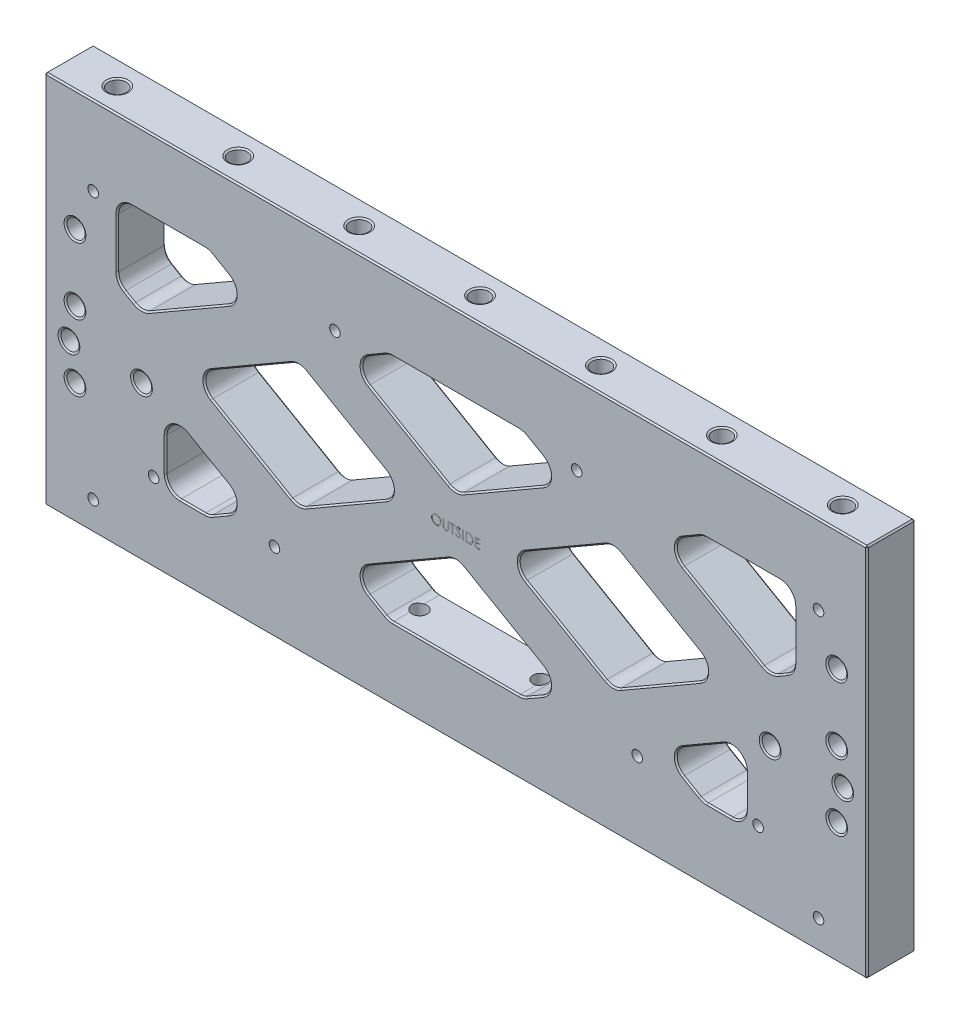
from build123d import *

# Parameters (mm, degrees)
SKETCH1_W                              = 431.8
SKETCH1_H                              = 196.85
EXTRUDE1_DEPTH                         = 25.4
SKETCH8_W                              = 355.6
SKETCH8_H                              = 120.65
EXTRUDE2_DEPTH                         = 26.4
EXTRUDE3_DEPTH                         = 25.4
EXTRUDE16_DEPTH                        = 25.4
FILLET1_R                              = 7.62
CHAMFER2_SIZE                          = 0.762
CHAMFER6_SIZE                          = 0.762
F_3_8_16_TAPPED_HOLE1_AT_2_COUNT       = 2
F_3_8_16_TAPPED_HOLE1_AT_2_PITCH       = 127
F_3_8_16_TAPPED_HOLE1_AT_3_COUNT       = 2
F_3_8_16_TAPPED_HOLE1_AT_3_PITCH       = 254
F_3_8_16_TAPPED_HOLE2_AT_2_COUNT       = 2
F_3_8_16_TAPPED_HOLE2_AT_2_PITCH       = 127
F_3_8_16_TAPPED_HOLE2_AT_3_COUNT       = 2
F_3_8_16_TAPPED_HOLE2_AT_3_PITCH       = 127
F_3_8_16_TAPPED_HOLE2_AT_4_COUNT       = 2
F_3_8_16_TAPPED_HOLE2_AT_4_PITCH       = 254
F_3_8_16_TAPPED_HOLE3_AT_2_COUNT       = 2
F_3_8_16_TAPPED_HOLE3_AT_2_PITCH       = 63.5
F_3_8_16_TAPPED_HOLE4_AT_2_COUNT       = 2
F_3_8_16_TAPPED_HOLE4_AT_2_PITCH       = 63.5
F_3_8_16_TAPPED_HOLE4_AT_3_COUNT       = 2
F_3_8_16_TAPPED_HOLE4_AT_3_PITCH       = 254
F_3_8_16_TAPPED_HOLE4_AT_4_COUNT       = 2
F_3_8_16_TAPPED_HOLE4_AT_4_PITCH       = 317.5
F_7_32_0_21875_DIAMETER_HOLE1_D        = 5.55625
F_3_8_16_TAPPED_HOLE5_AT_2_COUNT       = 2
F_3_8_16_TAPPED_HOLE5_AT_2_PITCH       = 34.925
F_3_8_16_TAPPED_HOLE5_AT_3_COUNT       = 2
F_3_8_16_TAPPED_HOLE5_AT_3_PITCH       = 69.85
F_3_8_16_TAPPED_HOLE5_AT_4_COUNT       = 2
F_3_8_16_TAPPED_HOLE5_AT_4_PITCH       = 400.05
F_3_8_16_TAPPED_HOLE5_AT_5_COUNT       = 2
F_3_8_16_TAPPED_HOLE5_AT_5_PITCH       = 401.571610208
F_3_8_16_TAPPED_HOLE5_AT_6_COUNT       = 2
F_3_8_16_TAPPED_HOLE5_AT_6_PITCH       = 406.102234665
F_3_8_16_TAPPED_HOLE6_AT_2_COUNT       = 2
F_3_8_16_TAPPED_HOLE6_AT_2_PITCH       = 38.1
F_3_8_16_TAPPED_HOLE6_AT_3_COUNT       = 2
F_3_8_16_TAPPED_HOLE6_AT_3_PITCH       = 368.3
F_3_8_16_TAPPED_HOLE6_AT_4_COUNT       = 2
F_3_8_16_TAPPED_HOLE6_AT_4_PITCH       = 406.4
F_3_8_0_375_DIAMETER_HOLE1_D           = 9.54278
F_3_8_0_375_DIAMETER_HOLE1_DEPTH       = 19.05
F_3_8_0_375_DIAMETER_HOLE1_CSINK_D     = 14.224
F_3_8_0_375_DIAMETER_HOLE1_CSINK_ANGLE = 90
F_3_8_0_375_DIAMETER_HOLE1_TIP         = 2.866940349
EXTRUDE15_DEPTH                        = 19.05
CHAMFER5_SIZE                          = 2.286
F_7_32_0_21875_DIAMETER_HOLE2_D        = 5.55625
SKETCH59_W                             = 0.427403846
SKETCH59_H                             = 4.7625
EXTRUDE17_DEPTH                        = 0.0254


with BuildPart() as part:
    # Sketch1 → Extrude1 (new body)
    with BuildSketch(Plane.XY):
        with Locations((0, 98.425)):
            Rectangle(SKETCH1_W, SKETCH1_H)
    extrude(amount=EXTRUDE1_DEPTH)

    # Sketch8 → Extrude2 (cut, through all)
    with BuildSketch(Plane.XY.offset(25.4)):
        with Locations((0, 98.425)):
            Rectangle(SKETCH8_W, SKETCH8_H)
    extrude(amount=-EXTRUDE2_DEPTH, mode=Mode.SUBTRACT)

    # Sketch9 → Extrude3 (add)
    with BuildSketch(Plane.XY.offset(25.4)):
        Polygon((-129.885964967, 158.75), (79.085964967, 38.1), (129.885964967, 38.1), (-79.085964967, 158.75), align=None)
        Polygon((-177.8, 91.092651581), (-86.014035033, 38.1), (-35.214035033, 38.1), (-177.8, 120.422045256), align=None)
        Polygon((35.214035033, 158.75), (177.8, 76.427954744), (177.8, 105.757348419), (86.014035033, 158.75), align=None)
    extrude3 = extrude(amount=-EXTRUDE3_DEPTH)

    # Mirror2: Extrude3 across plane
    add(extrude3.mirror(Plane(origin=(0, 0, 0), x_dir=(0, 0, 1), z_dir=(1, 0, 0))))

    # Sketch56 → Extrude16 (add)
    with BuildSketch(Plane.XY.offset(25.4)):
        Polygon((-177.8, 76.427954744), (-177.8, 38.1), (-152.4, 38.1), (-152.4, 76.427954744), (-165.1, 83.760303163), align=None)
        Polygon((165.1, 83.760303163), (177.8, 76.427954744), (177.8, 38.1), (152.4, 38.1), (152.4, 76.427954744), align=None)
    extrude(amount=-EXTRUDE16_DEPTH)

    # Fillet1
    fillet1_edges = [part.edges().sort_by_distance(p)[0] for p in [
        (82.55, 65.429432116, 12.7),
        (57.15, 50.764735278, 12.7),
        (165.1, 113.089696837, 12.7),
        (139.7, 98.425, 12.7),
        (107.95, 50.764735278, 12.7),
        (35.214035033, 38.1, 12.7),
        (177.8, 120.422045256, 12.7),
        (-107.95, 146.085264722, 12.7),
        (-165.1, 113.089696837, 12.7),
        (-57.15, 146.085264722, 12.7),
        (-82.55, 131.420567884, 12.7),
        (-35.214035033, 158.75, 12.7),
        (-139.7, 98.425, 12.7),
        (-177.8, 158.75, 12.7),
        (177.8, 158.75, 12.7),
        (-152.4, 76.427954744, 12.7),
        (-152.4, 38.1, 12.7),
        (152.4, 76.427954744, 12.7),
        (152.4, 38.1, 12.7),
        (-129.885964967, 158.75, 12.7),
        (129.885964967, 38.1, 12.7),
        (-177.8, 120.422045256, 12.7),
        (-35.214035033, 38.1, 12.7),
        (35.214035033, 158.75, 12.7),
        (82.55, 131.420567884, 12.7),
        (57.15, 146.085264722, 12.7),
        (0, 113.089696837, 12.7),
        (-25.4, 98.425, 12.7),
        (-82.55, 65.429432116, 12.7),
        (-107.95, 50.764735278, 12.7),
        (25.4, 98.425, 12.7),
        (0, 83.760303163, 12.7),
        (-57.15, 50.764735278, 12.7),
        (107.95, 146.085264722, 12.7),
        (129.885964967, 158.75, 12.7),
        (-129.885964967, 38.1, 12.7),
    ]]
    fillet(fillet1_edges, radius=FILLET1_R)

    # Chamfer2
    chamfer2_edges = [part.edges().sort_by_distance(p)[0] for p in [
        (215.9, 98.425, 25.4),
        (0, 196.85, 25.4),
        (-215.9, 98.425, 25.4),
        (0, 196.85, 0),
        (215.9, 98.425, 0),
        (0, 0, 0),
        (-215.9, 98.425, 0),
        (0, 0, 25.4),
        (-215.9, 196.85, 12.7),
        (215.9, 196.85, 12.7),
        (215.9, 0, 12.7),
        (-215.9, 0, 12.7),
    ]]
    chamfer(chamfer2_edges, length=CHAMFER2_SIZE)

    # Chamfer6
    chamfer6_edges = [part.edges().sort_by_distance(p)[0] for p in [
        (152.4, 54.474863795, 0),
        (152.4, 54.474863795, 25.4),
        (138.353868906, 38.1, 25.4),
        (138.353868906, 38.1, 0),
        (130.175, 63.596345011, 0),
        (130.175, 63.596345011, 25.4),
        (-138.353868906, 38.1, 0),
        (-138.353868906, 38.1, 25.4),
        (-152.4, 54.474863795, 0),
        (-152.4, 54.474863795, 25.4),
        (-130.175, 63.596345011, 0),
        (-130.175, 63.596345011, 25.4),
        (140.335, 127.387776254, 25.4),
        (140.335, 127.387776254, 0),
        (123.748868906, 155.206745938, 0),
        (123.748868906, 155.206745938, 25.4),
        (151.053868906, 158.75, 0),
        (151.053868906, 158.75, 25.4),
        (177.8, 137.975727154, 25.4),
        (177.8, 137.975727154, 0),
        (171.45, 116.755871047, 25.4),
        (171.45, 116.755871047, 0),
        (57.785, 79.727511532, 25.4),
        (57.785, 79.727511532, 0),
        (57.785, 117.122488468, 0),
        (57.785, 117.122488468, 25.4),
        (107.315, 117.122488468, 0),
        (107.315, 117.122488468, 25.4),
        (107.315, 79.727511532, 25.4),
        (107.315, 79.727511532, 0),
        (41.351131094, 41.643254062, 0),
        (41.351131094, 41.643254062, 25.4),
        (0, 38.1, 0),
        (0, 38.1, 25.4),
        (-41.351131094, 41.643254062, 0),
        (-41.351131094, 41.643254062, 25.4),
        (-24.765, 69.462223746, 25.4),
        (-24.765, 69.462223746, 0),
        (24.765, 69.462223746, 0),
        (24.765, 69.462223746, 25.4),
        (123.748868906, 41.643254062, 0),
        (123.748868906, 41.643254062, 25.4),
        (-123.748868906, 41.643254062, 0),
        (-123.748868906, 41.643254062, 25.4),
        (-57.785, 117.122488468, 25.4),
        (-57.785, 117.122488468, 0),
        (-57.785, 79.727511532, 0),
        (-57.785, 79.727511532, 25.4),
        (-107.315, 79.727511532, 0),
        (-107.315, 79.727511532, 25.4),
        (-107.315, 117.122488468, 25.4),
        (-107.315, 117.122488468, 0),
        (-171.45, 116.755871047, 25.4),
        (-171.45, 116.755871047, 0),
        (-140.335, 127.387776254, 0),
        (-140.335, 127.387776254, 25.4),
        (-177.8, 137.975727154, 25.4),
        (-177.8, 137.975727154, 0),
        (-151.053868906, 158.75, 0),
        (-151.053868906, 158.75, 25.4),
        (-123.748868906, 155.206745938, 0),
        (-123.748868906, 155.206745938, 25.4),
        (-41.351131094, 155.206745938, 0),
        (-41.351131094, 155.206745938, 25.4),
        (0, 158.75, 0),
        (0, 158.75, 25.4),
        (41.351131094, 155.206745938, 0),
        (41.351131094, 155.206745938, 25.4),
        (24.765, 127.387776254, 25.4),
        (24.765, 127.387776254, 0),
        (-24.765, 127.387776254, 0),
        (-24.765, 127.387776254, 25.4),
        (150.168153673, 40.331846327, 25.4),
        (150.168153673, 40.331846327, 0),
        (148.59, 69.828841167, 25.4),
        (148.59, 69.828841167, 0),
        (-150.168153673, 40.331846327, 25.4),
        (-150.168153673, 40.331846327, 0),
        (-148.59, 69.828841167, 25.4),
        (-148.59, 69.828841167, 0),
        (115.57, 146.085264722, 25.4),
        (115.57, 146.085264722, 0),
        (129.955536689, 158.490354796, 25.4),
        (129.955536689, 158.490354796, 0),
        (175.568153673, 156.518153673, 25.4),
        (175.568153673, 156.518153673, 0),
        (176.779113577, 121.011454307, 25.4),
        (176.779113577, 121.011454307, 0),
        (165.1, 114.26851494, 0),
        (165.1, 114.26851494, 25.4),
        (33.02, 98.425, 25.4),
        (33.02, 98.425, 0),
        (82.55, 130.241749782, 0),
        (82.55, 130.241749782, 25.4),
        (132.08, 98.425, 25.4),
        (132.08, 98.425, 0),
        (82.55, 66.608250218, 0),
        (82.55, 66.608250218, 25.4),
        (35.144463311, 38.359645204, 25.4),
        (35.144463311, 38.359645204, 0),
        (-35.144463311, 38.359645204, 25.4),
        (-35.144463311, 38.359645204, 0),
        (-49.53, 50.764735278, 25.4),
        (-49.53, 50.764735278, 0),
        (0, 82.58148506, 0),
        (0, 82.58148506, 25.4),
        (49.53, 50.764735278, 25.4),
        (49.53, 50.764735278, 0),
        (129.955536689, 38.359645204, 25.4),
        (129.955536689, 38.359645204, 0),
        (115.57, 50.764735278, 25.4),
        (115.57, 50.764735278, 0),
        (-115.57, 50.764735278, 25.4),
        (-115.57, 50.764735278, 0),
        (-129.955536689, 38.359645204, 25.4),
        (-129.955536689, 38.359645204, 0),
        (-33.02, 98.425, 25.4),
        (-33.02, 98.425, 0),
        (-82.55, 66.608250218, 0),
        (-82.55, 66.608250218, 25.4),
        (-82.55, 130.241749782, 0),
        (-82.55, 130.241749782, 25.4),
        (-165.1, 114.26851494, 0),
        (-165.1, 114.26851494, 25.4),
        (-176.779113577, 121.011454307, 25.4),
        (-176.779113577, 121.011454307, 0),
        (-175.568153673, 156.518153673, 25.4),
        (-175.568153673, 156.518153673, 0),
        (-129.955536689, 158.490354796, 25.4),
        (-129.955536689, 158.490354796, 0),
        (-115.57, 146.085264722, 25.4),
        (-115.57, 146.085264722, 0),
        (-35.144463311, 158.490354796, 25.4),
        (-35.144463311, 158.490354796, 0),
        (35.144463311, 158.490354796, 25.4),
        (35.144463311, 158.490354796, 0),
        (49.53, 146.085264722, 25.4),
        (49.53, 146.085264722, 0),
        (0, 114.26851494, 0),
        (0, 114.26851494, 25.4),
        (-49.53, 146.085264722, 25.4),
        (-49.53, 146.085264722, 0),
        (-132.08, 98.425, 25.4),
        (-132.08, 98.425, 0),
    ]]
    chamfer(chamfer6_edges, length=CHAMFER6_SIZE)

    # Sketch6 → 3/8-16 Tapped Hole1 (revolve, cut)
    with BuildSketch(Plane(origin=(-127, 196.85, 12.7), x_dir=(0, 0, 1), z_dir=(1, 0, 0))):
        Polygon((0, 0), (0, 45.564665582), (3.96875, 43.18), (3.96875, 25.4), (4.7625, 25.4), (4.7625, 0.549926131), (5.715, 0), align=None)
    f_3_8_16_tapped_hole1 = revolve(axis=Axis((-127, 203.2, 12.7), (0, -1, 0)), mode=Mode.SUBTRACT)

    # 3/8-16 Tapped Hole1 at 2: 3/8-16 Tapped Hole1 ×2
    with Locations(*[(i * F_3_8_16_TAPPED_HOLE1_AT_2_PITCH, 0, 0) for i in range(1, F_3_8_16_TAPPED_HOLE1_AT_2_COUNT)]):
        add(f_3_8_16_tapped_hole1, mode=Mode.SUBTRACT)

    # 3/8-16 Tapped Hole1 at 3: 3/8-16 Tapped Hole1 ×2
    with Locations(*[(i * F_3_8_16_TAPPED_HOLE1_AT_3_PITCH, 0, 0) for i in range(1, F_3_8_16_TAPPED_HOLE1_AT_3_COUNT)]):
        add(f_3_8_16_tapped_hole1, mode=Mode.SUBTRACT)

    # Sketch48 → 3/8-16 Tapped Hole2 (revolve, cut)
    with BuildSketch(Plane(origin=(63.5, 196.85, 12.7), x_dir=(0, 0, 1), z_dir=(1, 0, 0))):
        Polygon((0, 0), (0, 45.564665582), (3.96875, 43.18), (3.96875, 25.4), (4.7625, 25.4), (4.7625, 0.549926131), (5.715, 0), align=None)
    f_3_8_16_tapped_hole2 = revolve(axis=Axis((63.5, 203.2, 12.7), (0, -1, 0)), mode=Mode.SUBTRACT)

    # 3/8-16 Tapped Hole2 at 2: 3/8-16 Tapped Hole2 ×2
    with Locations(*[(-i * F_3_8_16_TAPPED_HOLE2_AT_2_PITCH, 0, 0) for i in range(1, F_3_8_16_TAPPED_HOLE2_AT_2_COUNT)]):
        add(f_3_8_16_tapped_hole2, mode=Mode.SUBTRACT)

    # 3/8-16 Tapped Hole2 at 3: 3/8-16 Tapped Hole2 ×2
    with Locations(*[(i * F_3_8_16_TAPPED_HOLE2_AT_3_PITCH, 0, 0) for i in range(1, F_3_8_16_TAPPED_HOLE2_AT_3_COUNT)]):
        add(f_3_8_16_tapped_hole2, mode=Mode.SUBTRACT)

    # 3/8-16 Tapped Hole2 at 4: 3/8-16 Tapped Hole2 ×2
    with Locations(*[(-i * F_3_8_16_TAPPED_HOLE2_AT_4_PITCH, 0, 0) for i in range(1, F_3_8_16_TAPPED_HOLE2_AT_4_COUNT)]):
        add(f_3_8_16_tapped_hole2, mode=Mode.SUBTRACT)

    # Sketch26 → 3/8-16 Tapped Hole3 (revolve, cut)
    with BuildSketch(Plane(origin=(-31.75, 0, 12.7), x_dir=(0, 0, -1), z_dir=(1, 0, 0))):
        Polygon((0, 0), (0, 45.564665582), (3.96875, 43.18), (3.96875, 25.4), (4.7625, 25.4), (4.7625, 0.549926131), (5.715, 0), align=None)
    f_3_8_16_tapped_hole3 = revolve(axis=Axis((-31.75, -6.35, 12.7), (0, 1, 0)), mode=Mode.SUBTRACT)

    # 3/8-16 Tapped Hole3 at 2: 3/8-16 Tapped Hole3 ×2
    with Locations(*[(i * F_3_8_16_TAPPED_HOLE3_AT_2_PITCH, 0, 0) for i in range(1, F_3_8_16_TAPPED_HOLE3_AT_2_COUNT)]):
        add(f_3_8_16_tapped_hole3, mode=Mode.SUBTRACT)

    # Sketch32 → 3/8-16 Tapped Hole4 (revolve, cut)
    with BuildSketch(Plane(origin=(-158.75, 0, 12.7), x_dir=(0, 0, -1), z_dir=(1, 0, 0))):
        Polygon((0, 0), (0, 45.564665582), (3.96875, 43.18), (3.96875, 25.4), (4.7625, 25.4), (4.7625, 0.549926131), (5.715, 0), align=None)
    f_3_8_16_tapped_hole4 = revolve(axis=Axis((-158.75, -6.35, 12.7), (0, 1, 0)), mode=Mode.SUBTRACT)

    # 3/8-16 Tapped Hole4 at 2: 3/8-16 Tapped Hole4 ×2
    with Locations(*[(i * F_3_8_16_TAPPED_HOLE4_AT_2_PITCH, 0, 0) for i in range(1, F_3_8_16_TAPPED_HOLE4_AT_2_COUNT)]):
        add(f_3_8_16_tapped_hole4, mode=Mode.SUBTRACT)

    # 3/8-16 Tapped Hole4 at 3: 3/8-16 Tapped Hole4 ×2
    with Locations(*[(i * F_3_8_16_TAPPED_HOLE4_AT_3_PITCH, 0, 0) for i in range(1, F_3_8_16_TAPPED_HOLE4_AT_3_COUNT)]):
        add(f_3_8_16_tapped_hole4, mode=Mode.SUBTRACT)

    # 3/8-16 Tapped Hole4 at 4: 3/8-16 Tapped Hole4 ×2
    with Locations(*[(i * F_3_8_16_TAPPED_HOLE4_AT_4_PITCH, 0, 0) for i in range(1, F_3_8_16_TAPPED_HOLE4_AT_4_COUNT)]):
        add(f_3_8_16_tapped_hole4, mode=Mode.SUBTRACT)

    # 7/32 (0.21875) Diameter Hole1 (through all)
    with Locations(Plane.XY.offset(25.4)):
        with Locations((-190.5, 155.448), (-63.5, 155.448), (63.5, 155.448), (190.5, 155.448), (-158.75, 41.402), (-95.25, 41.402), (95.25, 41.402), (158.75, 41.402)):
            Hole(F_7_32_0_21875_DIAMETER_HOLE1_D / 2)

    # Sketch28 → 3/8-16 Tapped Hole5 (revolve, cut)
    with BuildSketch(Plane(origin=(200.025, 133.35, 0), x_dir=(0, 1, 0), z_dir=(1, 0, 0))):
        Polygon((0, 0), (0, 25.4), (5.715, 25.4), (4.7625, 24.850073869), (4.7625, 0.549926131), (5.715, 0), align=None)
    f_3_8_16_tapped_hole5 = revolve(axis=Axis((200.025, 133.35, -6.35), (0, 0, 1)), mode=Mode.SUBTRACT)

    # 3/8-16 Tapped Hole5 at 2: 3/8-16 Tapped Hole5 ×2
    with Locations(*[(0, -i * F_3_8_16_TAPPED_HOLE5_AT_2_PITCH, 0) for i in range(1, F_3_8_16_TAPPED_HOLE5_AT_2_COUNT)]):
        add(f_3_8_16_tapped_hole5, mode=Mode.SUBTRACT)

    # 3/8-16 Tapped Hole5 at 3: 3/8-16 Tapped Hole5 ×2
    with Locations(*[(0, -i * F_3_8_16_TAPPED_HOLE5_AT_3_PITCH, 0) for i in range(1, F_3_8_16_TAPPED_HOLE5_AT_3_COUNT)]):
        add(f_3_8_16_tapped_hole5, mode=Mode.SUBTRACT)

    # 3/8-16 Tapped Hole5 at 4: 3/8-16 Tapped Hole5 ×2
    with Locations(*[(-i * F_3_8_16_TAPPED_HOLE5_AT_4_PITCH, 0, 0) for i in range(1, F_3_8_16_TAPPED_HOLE5_AT_4_COUNT)]):
        add(f_3_8_16_tapped_hole5, mode=Mode.SUBTRACT)

    # 3/8-16 Tapped Hole5 at 5: 3/8-16 Tapped Hole5 ×2
    with Locations(*[Vector(-0.996210862, -0.08697079, 0) * (i * F_3_8_16_TAPPED_HOLE5_AT_5_PITCH) for i in range(1, F_3_8_16_TAPPED_HOLE5_AT_5_COUNT)]):
        add(f_3_8_16_tapped_hole5, mode=Mode.SUBTRACT)

    # 3/8-16 Tapped Hole5 at 6: 3/8-16 Tapped Hole5 ×2
    with Locations(*[Vector(-0.985096771, -0.172001023, 0) * (i * F_3_8_16_TAPPED_HOLE5_AT_6_PITCH) for i in range(1, F_3_8_16_TAPPED_HOLE5_AT_6_COUNT)]):
        add(f_3_8_16_tapped_hole5, mode=Mode.SUBTRACT)

    # Sketch44 → 3/8-16 Tapped Hole6 (revolve, cut)
    with BuildSketch(Plane(origin=(-203.2, 80.9625, 25.4), x_dir=(0, -1, 0), z_dir=(1, 0, 0))):
        Polygon((0, 0), (0, 25.4), (5.715, 25.4), (4.7625, 24.850073869), (4.7625, 0.549926131), (5.715, 0), align=None)
    f_3_8_16_tapped_hole6 = revolve(axis=Axis((-203.2, 80.9625, 31.75), (0, 0, -1)), mode=Mode.SUBTRACT)

    # 3/8-16 Tapped Hole6 at 2: 3/8-16 Tapped Hole6 ×2
    with Locations(*[(i * F_3_8_16_TAPPED_HOLE6_AT_2_PITCH, 0, 0) for i in range(1, F_3_8_16_TAPPED_HOLE6_AT_2_COUNT)]):
        add(f_3_8_16_tapped_hole6, mode=Mode.SUBTRACT)

    # 3/8-16 Tapped Hole6 at 3: 3/8-16 Tapped Hole6 ×2
    with Locations(*[(i * F_3_8_16_TAPPED_HOLE6_AT_3_PITCH, 0, 0) for i in range(1, F_3_8_16_TAPPED_HOLE6_AT_3_COUNT)]):
        add(f_3_8_16_tapped_hole6, mode=Mode.SUBTRACT)

    # 3/8-16 Tapped Hole6 at 4: 3/8-16 Tapped Hole6 ×2
    with Locations(*[(i * F_3_8_16_TAPPED_HOLE6_AT_4_PITCH, 0, 0) for i in range(1, F_3_8_16_TAPPED_HOLE6_AT_4_COUNT)]):
        add(f_3_8_16_tapped_hole6, mode=Mode.SUBTRACT)

    # 3/8 (0.375) Diameter Hole1
    with Locations(Plane.XZ):
        with Locations((-190.5, 12.7)):
            CounterSinkHole(F_3_8_0_375_DIAMETER_HOLE1_D / 2, F_3_8_0_375_DIAMETER_HOLE1_CSINK_D / 2, depth=F_3_8_0_375_DIAMETER_HOLE1_DEPTH, counter_sink_angle=F_3_8_0_375_DIAMETER_HOLE1_CSINK_ANGLE)
            with Locations((0, 0, -(F_3_8_0_375_DIAMETER_HOLE1_DEPTH + F_3_8_0_375_DIAMETER_HOLE1_TIP / 2))):  # 118° drill point
                Cone(0, F_3_8_0_375_DIAMETER_HOLE1_D / 2, F_3_8_0_375_DIAMETER_HOLE1_TIP, mode=Mode.SUBTRACT)

    # Sketch53 → Extrude15 (cut)
    with BuildSketch(Plane.XZ):
        with BuildLine():
            Line((187.96, 17.47139), (193.04, 17.47139))
            ThreePointArc((193.04, 17.47139), (197.81139, 12.7), (193.04, 7.92861))
            Line((193.04, 7.92861), (187.96, 7.92861))
            ThreePointArc((187.96, 7.92861), (183.18861, 12.7), (187.96, 17.47139))
        make_face()
    extrude(amount=-EXTRUDE15_DEPTH, mode=Mode.SUBTRACT)

    # Chamfer5
    chamfer5_edges = [part.edges().sort_by_distance(p)[0] for p in [
        (183.18861, 0, 12.7),
        (190.5, 0, 7.92861),
        (197.81139, 0, 12.7),
        (190.5, 0, 17.47139),
    ]]
    chamfer(chamfer5_edges, length=CHAMFER5_SIZE)

    # 7/32 (0.21875) Diameter Hole2 (through all)
    with Locations(Plane.XY.offset(25.4)):
        with Locations((-190.5, 15.24), (190.5, 15.24)):
            Hole(F_7_32_0_21875_DIAMETER_HOLE2_D / 2)

    # Sketch59 → Extrude17 (cut)
    with BuildSketch(Plane.XY.offset(25.4)):
        with BuildLine():
            add(Edge.make_bspline(
                [(-10.196634615, 98.734900316), (-10.1084493, 98.732666731), (-9.935246064, 98.728279787), (-9.680690579, 98.694698579), (-9.437673681, 98.636602351), (-9.204215742, 98.559228079), (-8.983109228, 98.456011933), (-8.772689878, 98.331254642), (-8.573458346, 98.183649175), (-8.388099966, 98.014336548), (-8.218477473, 97.830118349), (-8.06903582, 97.633525192), (-7.943792556, 97.425745751), (-7.840941896, 97.207404406), (-7.760253431, 96.97899495), (-7.704574303, 96.739299682), (-7.669007749, 96.48987165), (-7.664849709, 96.319745809), (-7.662740385, 96.233442984)],
                knots=[0, 0, 0, 0, 1.065120563, 2.091984664, 3.0946048, 4.079830382, 5.057816894, 6.036188127, 7.030412546, 8.04752943, 9.064399622, 10.05169764, 11.02544977, 11.989514704, 12.962713494, 13.945757189, 14.957906945, 16, 16, 16, 16], degree=3))
            add(Edge.make_bspline(
                [(-7.662740385, 96.233442984), (-7.6648494, 96.147775887), (-7.669006513, 95.978916115), (-7.704614743, 95.731070929), (-7.760459818, 95.492822517), (-7.840192594, 95.264568611), (-7.942552978, 95.046068426), (-8.068630193, 94.837896892), (-8.217140197, 94.639985764), (-8.386150234, 94.454503173), (-8.570392366, 94.284417329), (-8.768009265, 94.136209859), (-8.974556604, 94.008678104), (-9.192692314, 93.90691889), (-9.419523435, 93.825586384), (-9.657080096, 93.770133698), (-9.904249157, 93.734364543), (-10.072802202, 93.730257205), (-10.158473558, 93.728169547)],
                knots=[0, 0, 0, 0, 1.043624062, 2.057103931, 3.04512605, 4.022047818, 4.998200453, 5.980619268, 6.982898556, 8.009068085, 9.034988726, 10.034168286, 11.015286542, 11.987931943, 12.962482838, 13.94673481, 14.956375938, 16, 16, 16, 16], degree=3))
            add(Edge.make_bspline(
                [(-10.158473558, 93.728169547), (-10.244775935, 93.730277819), (-10.414900893, 93.734433786), (-10.664642359, 93.770059198), (-10.904506003, 93.825768615), (-11.133805888, 93.905383241), (-11.352669882, 94.008276687), (-11.56152603, 94.133740502), (-11.759536012, 94.282612362), (-11.945058174, 94.451567594), (-12.114806191, 94.635497456), (-12.262796627, 94.832575496), (-12.388288656, 95.038935242), (-12.490836619, 95.255149373), (-12.572022901, 95.480172658), (-12.627410529, 95.715506122), (-12.663246235, 95.959808092), (-12.667375794, 96.12614575), (-12.669471154, 96.210546349)],
                knots=[0, 0, 0, 0, 1.053102029, 2.075944431, 3.073151272, 4.055350789, 5.033113405, 6.020478099, 7.024410459, 8.052272461, 9.079885166, 10.07527673, 11.055994387, 12.023226415, 12.992069828, 13.970394897, 14.97016774, 16, 16, 16, 16], degree=3))
            add(Edge.make_bspline(
                [(-12.669471154, 96.210546349), (-12.668743668, 96.267196517), (-12.667297873, 96.379782185), (-12.649892034, 96.546968523), (-12.624634862, 96.711466168), (-12.58843726, 96.872807351), (-12.541095741, 97.03059712), (-12.485235661, 97.185923693), (-12.417009658, 97.337212974), (-12.33988349, 97.485181661), (-12.253802244, 97.627523133), (-12.158721314, 97.762069994), (-12.05798033, 97.889951279), (-11.947540141, 98.007853095), (-11.831040621, 98.11920532), (-11.706591899, 98.222296732), (-11.574953345, 98.318056933), (-11.435558536, 98.404353897), (-11.29184224, 98.482403291), (-11.143692053, 98.549380167), (-10.993120076, 98.606864986), (-10.839421072, 98.653456966), (-10.683003193, 98.690239844), (-10.523525051, 98.715286993), (-10.361113696, 98.732737225), (-10.251696865, 98.734176183), (-10.196634615, 98.734900316)],
                knots=[0, 0, 0, 0, 1.037015668, 2.060948919, 3.074880161, 4.083647147, 5.086022904, 6.090072063, 7.104153813, 8.122640571, 9.144368836, 10.147691507, 11.138137339, 12.123020368, 13.103399296, 14.087645067, 15.080126199, 16.082011238, 17.087798457, 18.072939717, 19.057185487, 20.037253025, 21.01195951, 21.997135196, 22.992090687, 24, 24, 24, 24], degree=3))
        make_face()
        with BuildLine():
            add(Edge.make_bspline(
                [(-10.175646034, 98.246438777), (-10.22084166, 98.245887837), (-10.310800839, 98.244791225), (-10.444538012, 98.230346269), (-10.576516322, 98.209758813), (-10.706763025, 98.180392529), (-10.834733155, 98.140382014), (-10.961619546, 98.094334207), (-11.08626513, 98.03824408), (-11.208258415, 97.974871936), (-11.326525, 97.904728583), (-11.438120854, 97.827206286), (-11.54333488, 97.744123039), (-11.641909468, 97.655284946), (-11.73355517, 97.560239595), (-11.820075782, 97.460427887), (-11.89800332, 97.352996921), (-11.969421194, 97.240859903), (-12.033331005, 97.124162894), (-12.09016172, 97.004134475), (-12.136649175, 96.879795551), (-12.174561908, 96.752495072), (-12.205994151, 96.622434654), (-12.22590674, 96.48862766), (-12.240510415, 96.351746454), (-12.241544348, 96.259242574), (-12.242067308, 96.212454402)],
                knots=[0, 0, 0, 0, 1.008559885, 2.007477868, 2.99961109, 3.989939068, 4.984837346, 5.991145699, 7.001802488, 8.033829008, 9.059044045, 10.069351652, 11.065060232, 12.050310815, 13.029377138, 14.011219647, 14.996725999, 15.989392538, 16.977580475, 17.965360261, 18.951710183, 19.937753436, 20.929683414, 21.935841486, 22.955955122, 24, 24, 24, 24], degree=3))
            add(Edge.make_bspline(
                [(-12.242067308, 96.212454402), (-12.240332585, 96.143653666), (-12.236919848, 96.008301334), (-12.207041869, 95.809952538), (-12.161019825, 95.619332406), (-12.093178194, 95.437483951), (-12.008336822, 95.262844051), (-11.903525232, 95.096961952), (-11.779347691, 94.939792819), (-11.638291249, 94.7924339), (-11.484091424, 94.657933002), (-11.320352959, 94.539872792), (-11.148830014, 94.439982416), (-10.969075299, 94.3586048), (-10.782048469, 94.294120907), (-10.586544373, 94.24992677), (-10.383865355, 94.220840882), (-10.245711142, 94.218047668), (-10.175646034, 94.216631085)],
                knots=[0, 0, 0, 0, 1.032063989, 2.030389145, 3.003944642, 3.970395727, 4.937377036, 5.913328081, 6.909231446, 7.93887556, 8.970685674, 9.976071282, 10.964166581, 11.944589148, 12.933237628, 13.927779006, 14.949070134, 16, 16, 16, 16], degree=3))
            add(Edge.make_bspline(
                [(-10.175646034, 94.216631085), (-10.12855239, 94.217278111), (-10.035151552, 94.218561357), (-9.896228716, 94.231486342), (-9.759808656, 94.252212564), (-9.626082718, 94.282053921), (-9.495202671, 94.319401727), (-9.366622243, 94.363771528), (-9.241710998, 94.419127023), (-9.118893147, 94.480288343), (-9.001332547, 94.550011557), (-8.889106912, 94.624902754), (-8.785044953, 94.707863627), (-8.68654411, 94.795381793), (-8.594522147, 94.889221886), (-8.509601351, 94.989261902), (-8.432067671, 95.096133296), (-8.360676916, 95.208100224), (-8.296991048, 95.325116553), (-8.241502345, 95.445580151), (-8.194426916, 95.569194389), (-8.156424201, 95.696137563), (-8.126644341, 95.826168575), (-8.106124878, 95.959461531), (-8.091771467, 96.095749779), (-8.090689594, 96.187929812), (-8.090144231, 96.234397011)],
                knots=[0, 0, 0, 0, 1.047197238, 2.076906641, 3.100256066, 4.114471768, 5.12198147, 6.126382909, 7.136867548, 8.15857795, 9.17633901, 10.174870724, 11.156907918, 12.133735059, 13.104061851, 14.077631395, 15.04955518, 16.038496417, 17.029181396, 18.010275684, 18.986308667, 19.968651475, 20.955262928, 21.950658345, 22.966943676, 24, 24, 24, 24], degree=3))
            add(Edge.make_bspline(
                [(-8.090144231, 96.234397011), (-8.090690031, 96.280546322), (-8.091772726, 96.372091981), (-8.106118022, 96.507429738), (-8.126666019, 96.639763572), (-8.156278847, 96.768573961), (-8.194447092, 96.89389374), (-8.241510566, 97.015605207), (-8.297007706, 97.134161787), (-8.360700326, 97.249270455), (-8.432295428, 97.359726081), (-8.510528666, 97.465320792), (-8.596750801, 97.564071558), (-8.688498356, 97.658416267), (-8.788063025, 97.746342752), (-8.894993797, 97.827880182), (-9.007992515, 97.904996316), (-9.127636361, 97.974563599), (-9.251112955, 98.03880868), (-9.377814448, 98.093850937), (-9.506305473, 98.140621571), (-9.636259283, 98.180513584), (-9.768769692, 98.209643797), (-9.902941331, 98.230364822), (-10.038588569, 98.244786197), (-10.129815235, 98.245886169), (-10.175646034, 98.246438777)],
                knots=[0, 0, 0, 0, 1.02996197, 2.043119294, 3.035359645, 4.018872909, 4.991431989, 5.957985074, 6.929999688, 7.912076566, 8.892894881, 9.867085534, 10.843653904, 11.817741046, 12.803660682, 13.806313499, 14.818574707, 15.856120519, 16.894564902, 17.924820532, 18.937903209, 19.946497019, 20.957711757, 21.963978472, 22.977135795, 24, 24, 24, 24], degree=3))
        make_face(mode=Mode.SUBTRACT)
        with BuildLine():
            Line((-6.685817308, 98.612784931), (-6.258413462, 98.612784931))
            Line((-6.258413462, 98.612784931), (-6.258413462, 95.759291842))
            add(Edge.make_bspline(
                [(-6.258413462, 95.759291842), (-6.258477067, 95.718904841), (-6.258597769, 95.642263547), (-6.257791526, 95.533177395), (-6.2555336, 95.436195942), (-6.254110076, 95.350945358), (-6.25094324, 95.277816834), (-6.24836054, 95.216414179), (-6.24503964, 95.167028139), (-6.241048505, 95.13820695), (-6.239332933, 95.125818285)],
                knots=[0, 0, 0, 0, 1.528628734, 2.90083645, 4.128790002, 5.200304208, 6.127813768, 6.898992206, 7.526736466, 8, 8, 8, 8], degree=3))
            add(Edge.make_bspline(
                [(-6.239332933, 95.125818285), (-6.232287891, 95.081123224), (-6.218594769, 94.994251511), (-6.183697377, 94.870551313), (-6.134959991, 94.759066007), (-6.077207137, 94.656316715), (-6.001098833, 94.565163336), (-5.909926166, 94.481191408), (-5.799466416, 94.407751202), (-5.676647521, 94.340598848), (-5.544270108, 94.286626004), (-5.408999778, 94.245813604), (-5.272869867, 94.220941244), (-5.181734442, 94.218061239), (-5.136478365, 94.216631085)],
                knots=[0, 0, 0, 0, 1.035780045, 2.013197591, 2.933192213, 3.817615948, 4.702609284, 5.640816605, 6.646850145, 7.73207398, 8.84249596, 9.914020372, 10.964143139, 12, 12, 12, 12], degree=3))
            add(Edge.make_bspline(
                [(-5.136478365, 94.216631085), (-5.097624883, 94.218092288), (-5.020142325, 94.221006256), (-4.905017147, 94.239051274), (-4.792894142, 94.271573116), (-4.683219645, 94.313537215), (-4.580416341, 94.368983045), (-4.484426872, 94.433033008), (-4.398750947, 94.508159236), (-4.320567029, 94.591299348), (-4.252483777, 94.685106719), (-4.193468045, 94.787538756), (-4.145127405, 94.900136975), (-4.12125568, 94.979268528), (-4.108991887, 95.019921349)],
                knots=[0, 0, 0, 0, 0.994687771, 1.983630487, 2.973142513, 3.978332533, 4.983357753, 5.956394766, 6.925816176, 7.893390482, 8.871859704, 9.88551698, 10.913711441, 12, 12, 12, 12], degree=3))
            add(Edge.make_bspline(
                [(-4.108991887, 95.019921349), (-4.104909574, 95.036724231), (-4.095812534, 95.074167823), (-4.087312091, 95.137470007), (-4.078458569, 95.212158749), (-4.072315529, 95.29877068), (-4.066326726, 95.397015575), (-4.062743866, 95.507405232), (-4.061087832, 95.629538811), (-4.060594327, 95.714770092), (-4.060336538, 95.759291842)],
                knots=[0, 0, 0, 0, 0.558680831, 1.244966039, 2.062412453, 2.990489873, 4.051219941, 5.244515665, 6.560634259, 8, 8, 8, 8], degree=3))
            Line((-4.060336538, 95.759291842), (-4.060336538, 98.612784931))
            Line((-4.060336538, 98.612784931), (-3.632932692, 98.612784931))
            Line((-3.632932692, 98.612784931), (-3.632932692, 95.736395208))
            add(Edge.make_bspline(
                [(-3.632932692, 95.736395208), (-3.633278478, 95.684554199), (-3.633953298, 95.583383319), (-3.639805154, 95.435131648), (-3.649135572, 95.29449777), (-3.662318292, 95.16146278), (-3.679785785, 95.036502728), (-3.699210282, 94.918522311), (-3.723947432, 94.808368418), (-3.752840024, 94.705182164), (-3.785869388, 94.606958304), (-3.828651808, 94.513737654), (-3.876854431, 94.422686274), (-3.934024369, 94.335181312), (-3.998265572, 94.250835323), (-4.070998038, 94.170159832), (-4.149816271, 94.09186563), (-4.236030529, 94.017961065), (-4.328219636, 93.950185687), (-4.426109364, 93.890589434), (-4.528947755, 93.840210869), (-4.636467487, 93.798741843), (-4.748714445, 93.76756162), (-4.86569146, 93.744327212), (-4.987664791, 93.731125157), (-5.070620269, 93.729163102), (-5.112627704, 93.728169547)],
                knots=[0, 0, 0, 0, 1.316592851, 2.569410997, 3.76748051, 4.895814652, 5.963796859, 6.97159953, 7.931736103, 8.829262218, 9.692595152, 10.560224239, 11.431080259, 12.30701507, 13.211635791, 14.121146779, 15.063487852, 16.031507147, 17.00238618, 17.966455255, 18.938106653, 19.907068911, 20.888905087, 21.893141452, 22.933117798, 24, 24, 24, 24], degree=3))
            add(Edge.make_bspline(
                [(-5.112627704, 93.728169547), (-5.158441733, 93.729237388), (-5.248328694, 93.731332489), (-5.380777993, 93.743337731), (-5.507751953, 93.765950617), (-5.630591628, 93.794743255), (-5.747624619, 93.834453983), (-5.860418913, 93.880851789), (-5.96704269, 93.937834775), (-6.069225704, 94.001235071), (-6.164237247, 94.072570025), (-6.251455499, 94.150321476), (-6.331024452, 94.233243918), (-6.401602928, 94.32223513), (-6.464360274, 94.416602988), (-6.518421743, 94.516614454), (-6.564840122, 94.622230806), (-6.588797629, 94.695645696), (-6.600908954, 94.73275939)],
                knots=[0, 0, 0, 0, 1.13879206, 2.234305948, 3.301075583, 4.341971843, 5.366689343, 6.369221514, 7.369726634, 8.367512178, 9.355451585, 10.318319045, 11.268648973, 12.207971039, 13.137398894, 14.081662264, 15.030215811, 16, 16, 16, 16], degree=3))
            add(Edge.make_bspline(
                [(-6.600908954, 94.73275939), (-6.607953587, 94.758113001), (-6.623233553, 94.813105546), (-6.639596548, 94.904118946), (-6.65335212, 95.008914245), (-6.666286468, 95.127498615), (-6.673918658, 95.259963969), (-6.680609887, 95.406252887), (-6.685864447, 95.566542256), (-6.68583346, 95.678195008), (-6.685817308, 95.736395208)],
                knots=[0, 0, 0, 0, 0.625038921, 1.35572334, 2.194682327, 3.136881307, 4.189498639, 5.346923369, 6.617055217, 8, 8, 8, 8], degree=3))
            Line((-6.685817308, 95.736395208), (-6.685817308, 98.612784931))
        make_face()
        Polygon((-2.961298077, 98.124323393), (-2.961298077, 98.612784931), (-0.457932692, 98.612784931), (-0.457932692, 98.124323393), (-1.495913462, 98.124323393), (-1.495913462, 93.850284931), (-1.923317308, 93.850284931), (-1.923317308, 98.124323393), align=None)
        with BuildLine():
            Line((-0.213701923, 94.769012395), (0.188897236, 95.010381085))
            add(Edge.make_bspline(
                [(0.188897236, 95.010381085), (0.226341694, 94.947700618), (0.298083832, 94.827607263), (0.417760503, 94.665331144), (0.541766357, 94.527406209), (0.6710197, 94.414634825), (0.804731579, 94.325849733), (0.943774881, 94.262981696), (1.087681045, 94.223771387), (1.185616852, 94.219008769), (1.234510216, 94.216631085)],
                knots=[0, 0, 0, 0, 1.272034388, 2.437168799, 3.508375237, 4.49857839, 5.41946034, 6.295179144, 7.148887113, 8, 8, 8, 8], degree=3))
            add(Edge.make_bspline(
                [(1.234510216, 94.216631085), (1.276266266, 94.21779405), (1.359047732, 94.220099631), (1.480916355, 94.242253151), (1.599273736, 94.276287512), (1.71168049, 94.325029565), (1.816585594, 94.384000862), (1.90857899, 94.455229054), (1.988107451, 94.534975355), (2.053161996, 94.623942467), (2.103073044, 94.719624016), (2.141434395, 94.817834864), (2.16272287, 94.920117809), (2.165929738, 94.988984188), (2.167548077, 95.023737455)],
                knots=[0, 0, 0, 0, 1.095163259, 2.171163733, 3.241058638, 4.321873601, 5.38011039, 6.391990106, 7.366004449, 8.327778327, 9.272591725, 10.192022065, 11.087607919, 12, 12, 12, 12], degree=3))
            add(Edge.make_bspline(
                [(2.167548077, 95.023737455), (2.165541961, 95.063389826), (2.161463821, 95.143997301), (2.126994915, 95.262923257), (2.072771475, 95.380614933), (2.022748021, 95.453414869), (1.996777344, 95.491210412)],
                knots=[0, 0, 0, 0, 0.938893495, 1.908633276, 2.914225137, 4, 4, 4, 4], degree=3))
            add(Edge.make_bspline(
                [(1.996777344, 95.491210412), (1.975454115, 95.518488411), (1.930688664, 95.575755159), (1.853730049, 95.660997425), (1.763424729, 95.748924631), (1.662863106, 95.842894277), (1.54838201, 95.938535886), (1.423567071, 96.040410221), (1.285231606, 96.144643081), (1.188213362, 96.214546465), (1.138153546, 96.25061546)],
                knots=[0, 0, 0, 0, 0.722233717, 1.516239348, 2.393582979, 3.351407094, 4.387010283, 5.505090956, 6.712668013, 8, 8, 8, 8], degree=3))
            add(Edge.make_bspline(
                [(1.138153546, 96.25061546), (1.088046608, 96.286305074), (0.992245959, 96.354540898), (0.858271959, 96.455811084), (0.738468601, 96.54839935), (0.633368367, 96.633177309), (0.543017487, 96.71015646), (0.466703989, 96.778597585), (0.406371881, 96.840351644), (0.37282268, 96.880412899), (0.357759916, 96.898399414)],
                knots=[0, 0, 0, 0, 1.452282411, 2.77665338, 3.964542531, 5.026858415, 5.96415736, 6.766646006, 7.446254459, 8, 8, 8, 8], degree=3))
            add(Edge.make_bspline(
                [(0.357759916, 96.898399414), (0.336706203, 96.92643154), (0.29530125, 96.981560476), (0.240646792, 97.067727514), (0.194193146, 97.155933458), (0.157777258, 97.24641533), (0.127111903, 97.337902859), (0.10648629, 97.431589732), (0.093571211, 97.527055567), (0.092248615, 97.591299652), (0.091586538, 97.623459511)],
                knots=[0, 0, 0, 0, 1.068054152, 2.10047183, 3.106115577, 4.101338837, 5.06977816, 6.043150881, 7.020423561, 8, 8, 8, 8], degree=3))
            add(Edge.make_bspline(
                [(0.091586538, 97.623459511), (0.093362555, 97.673846454), (0.096876627, 97.773543355), (0.126595331, 97.919181735), (0.17350309, 98.058228253), (0.239218633, 98.189306314), (0.323933103, 98.309002881), (0.42196709, 98.418694804), (0.538732005, 98.510908482), (0.666846824, 98.591479176), (0.807077102, 98.654542738), (0.954021867, 98.702114643), (1.107914669, 98.729069383), (1.212149648, 98.732937574), (1.265039062, 98.734900316)],
                knots=[0, 0, 0, 0, 1.005424448, 1.989358655, 2.955360095, 3.929531133, 4.905563448, 5.876582895, 6.856512386, 7.866279853, 8.892233794, 9.918561126, 10.94386622, 12, 12, 12, 12], degree=3))
            add(Edge.make_bspline(
                [(1.265039062, 98.734900316), (1.321160499, 98.73296463), (1.432768124, 98.729115167), (1.596937235, 98.695644955), (1.754998781, 98.64026297), (1.882148367, 98.577413403), (1.98166116, 98.514641726), (2.057551914, 98.457464751), (2.134456017, 98.39164005), (2.212993799, 98.31699229), (2.291834482, 98.232836532), (2.372148536, 98.139749131), (2.454123774, 98.03829896), (2.506859426, 97.965875621), (2.533894231, 97.928747972)],
                knots=[0, 0, 0, 0, 1.286793592, 2.559021753, 3.825965368, 5.121522368, 5.803751409, 6.523245864, 7.299691795, 8.125521123, 9.008227632, 9.944561021, 10.946284179, 12, 12, 12, 12], degree=3))
            Line((2.533894231, 97.928747972), (2.147513522, 97.635861854))
            add(Edge.make_bspline(
                [(2.147513522, 97.635861854), (2.124182806, 97.665918251), (2.079253304, 97.723799843), (2.011041395, 97.804859383), (1.946749485, 97.878904665), (1.883407691, 97.943218999), (1.824361356, 98.001324402), (1.767052095, 98.051071786), (1.712304639, 98.092948578), (1.643293414, 98.137639279), (1.556591804, 98.181939379), (1.447755703, 98.219425803), (1.334018665, 98.241952512), (1.256553702, 98.244930963), (1.21733774, 98.246438777)],
                knots=[0, 0, 0, 0, 1.181633172, 2.275549214, 3.290209073, 4.226197932, 5.078386478, 5.862611352, 6.581680152, 7.217281963, 8.414376989, 9.595101626, 10.782541182, 12, 12, 12, 12], degree=3))
            add(Edge.make_bspline(
                [(1.21733774, 98.246438777), (1.168139044, 98.24479), (1.073263992, 98.241610488), (0.938566564, 98.206885079), (0.817335187, 98.152209048), (0.713169018, 98.075580453), (0.626441203, 97.984792245), (0.563704847, 97.88031816), (0.525944801, 97.764953534), (0.521337042, 97.684478637), (0.518990385, 97.643494066)],
                knots=[0, 0, 0, 0, 1.14458467, 2.207223713, 3.21896685, 4.227309161, 5.202851033, 6.127160689, 7.046193047, 8, 8, 8, 8], degree=3))
            add(Edge.make_bspline(
                [(0.518990385, 97.643494066), (0.519525318, 97.617978661), (0.520596058, 97.566906129), (0.535529622, 97.491452587), (0.554714781, 97.416189657), (0.585116719, 97.341455714), (0.627088364, 97.265943747), (0.682204336, 97.188353454), (0.751618878, 97.108000951), (0.804791527, 97.055739488), (0.832865084, 97.028147011)],
                knots=[0, 0, 0, 0, 0.858281714, 1.717966888, 2.583508476, 3.4729293, 4.427298488, 5.488583878, 6.674047936, 8, 8, 8, 8], degree=3))
            add(Edge.make_bspline(
                [(0.832865084, 97.028147011), (0.843290023, 97.018843772), (0.868057292, 96.996741406), (0.913336319, 96.96055691), (0.973129912, 96.915921709), (1.045876693, 96.860693968), (1.132917996, 96.79662955), (1.234263392, 96.724547599), (1.348783192, 96.642108099), (1.430047656, 96.584471589), (1.473016827, 96.553995869)],
                knots=[0, 0, 0, 0, 0.420754252, 0.999615792, 1.744751191, 2.668019286, 3.750313428, 4.999500688, 6.413464383, 8, 8, 8, 8], degree=3))
            add(Edge.make_bspline(
                [(1.473016827, 96.553995869), (1.524704802, 96.516383876), (1.624791401, 96.443553465), (1.767200465, 96.3341307), (1.896323826, 96.227113558), (2.012614828, 96.123185457), (2.117222335, 96.02313473), (2.208985805, 95.925757688), (2.288840249, 95.831751963), (2.374809114, 95.711229994), (2.462653861, 95.563210018), (2.538093912, 95.381856415), (2.585662235, 95.19979785), (2.591882762, 95.077433119), (2.594951923, 95.01705927)],
                knots=[0, 0, 0, 0, 1.163667725, 2.253281268, 3.268753668, 4.215851969, 5.092017293, 5.902905408, 6.650798638, 7.335211899, 8.59617414, 9.77448103, 10.901945474, 12, 12, 12, 12], degree=3))
            add(Edge.make_bspline(
                [(2.594951923, 95.01705927), (2.594057746, 94.974362281), (2.592286756, 94.889797448), (2.571929227, 94.765625361), (2.542102825, 94.645024071), (2.497148589, 94.529484307), (2.442280291, 94.416892326), (2.372657647, 94.310201576), (2.291956833, 94.207050727), (2.199382317, 94.110190333), (2.098082714, 94.021272831), (1.991016687, 93.942175786), (1.878008994, 93.876224246), (1.759672685, 93.82240685), (1.635980577, 93.780315171), (1.506974271, 93.74981766), (1.372441114, 93.731100068), (1.281000459, 93.729157292), (1.234510216, 93.728169547)],
                knots=[0, 0, 0, 0, 0.983748083, 1.948392443, 2.894712957, 3.844097841, 4.80183111, 5.778335162, 6.776009319, 7.81870978, 8.863265674, 9.881300176, 10.883814829, 11.87499822, 12.874611388, 13.892143829, 14.928324115, 16, 16, 16, 16], degree=3))
            add(Edge.make_bspline(
                [(1.234510216, 93.728169547), (1.198539268, 93.728865119), (1.127050387, 93.730247503), (1.021309985, 93.742468459), (0.917705758, 93.759759197), (0.817537753, 93.787210342), (0.719515418, 93.820516514), (0.624065074, 93.861526174), (0.531140461, 93.910671366), (0.440220821, 93.966862096), (0.351537391, 94.032254956), (0.265921972, 94.108418892), (0.180565473, 94.193253311), (0.097987266, 94.289061971), (0.016517023, 94.394297005), (-0.062238955, 94.509943001), (-0.139910864, 94.635370043), (-0.188645483, 94.723632892), (-0.213701923, 94.769012395)],
                knots=[0, 0, 0, 0, 0.915332311, 1.819136955, 2.706846663, 3.586547465, 4.459518054, 5.340707479, 6.227863349, 7.133153174, 8.059268498, 9.028702269, 10.047606654, 11.120612155, 12.245963614, 13.433783089, 14.680604001, 16, 16, 16, 16], degree=3))
        make_face()
        with Locations((3.785576923, 96.231534931)):
            Rectangle(SKETCH59_W, SKETCH59_H)
        with BuildLine():
            Line((5.220432692, 93.850284931), (5.220432692, 98.612784931))
            Line((5.220432692, 98.612784931), (6.182091346, 98.612784931))
            add(Edge.make_bspline(
                [(6.182091346, 98.612784931), (6.265733077, 98.61218272), (6.427328464, 98.611019251), (6.660843973, 98.603642286), (6.876903307, 98.590592403), (7.074795876, 98.571583869), (7.255064954, 98.548243491), (7.417205774, 98.518987584), (7.562056726, 98.484441537), (7.651141929, 98.454988264), (7.693269231, 98.441060172)],
                knots=[0, 0, 0, 0, 1.314313732, 2.53924729, 3.670748893, 4.714932338, 5.66265055, 6.526160246, 7.303039223, 8, 8, 8, 8], degree=3))
            add(Edge.make_bspline(
                [(7.693269231, 98.441060172), (7.748371001, 98.42006339), (7.857325016, 98.378545964), (8.012456137, 98.300228283), (8.158495291, 98.211491883), (8.296225628, 98.112219799), (8.422501038, 97.999601168), (8.54225464, 97.878419919), (8.650587532, 97.744269356), (8.749794892, 97.599931604), (8.839242343, 97.447106991), (8.916992411, 97.286086718), (8.981563738, 97.117688517), (9.035166664, 96.94238069), (9.077412023, 96.759777762), (9.10623458, 96.569667108), (9.125245105, 96.372800069), (9.127155618, 96.239212673), (9.128125, 96.171431265)],
                knots=[0, 0, 0, 0, 0.984719456, 1.947108742, 2.898477687, 3.838006223, 4.779231079, 5.722358779, 6.681677486, 7.655904652, 8.64651281, 9.637519902, 10.640069247, 11.656948941, 12.698408672, 13.768548281, 14.867775369, 16, 16, 16, 16], degree=3))
            add(Edge.make_bspline(
                [(9.128125, 96.171431265), (9.127269155, 96.11256508), (9.125582623, 95.996563114), (9.110438804, 95.825601752), (9.088427454, 95.659712214), (9.054349456, 95.499684458), (9.012980322, 95.344116419), (8.959961245, 95.194666115), (8.899225087, 95.049962574), (8.828400074, 94.911962366), (8.750646975, 94.781220348), (8.667205603, 94.657972933), (8.578164957, 94.543978792), (8.482675971, 94.438892717), (8.381972614, 94.342873126), (8.275395578, 94.255117919), (8.162669855, 94.177344179), (8.044300336, 94.106495721), (7.916833889, 94.044691594), (7.777856157, 93.992399331), (7.626774447, 93.949065186), (7.463959598, 93.912909789), (7.289130295, 93.884229602), (7.10211513, 93.865007618), (6.90320144, 93.852008806), (6.76661394, 93.850870714), (6.696311599, 93.850284931)],
                knots=[0, 0, 0, 0, 1.105936401, 2.179363191, 3.223086493, 4.248585256, 5.251745608, 6.245858792, 7.225916811, 8.198733463, 9.158002045, 10.082870192, 10.993790845, 11.873723703, 12.748670949, 13.606408763, 14.465103618, 15.319838547, 16.196477973, 17.123216899, 18.106603292, 19.147568657, 20.255746949, 21.433717677, 22.679120308, 24, 24, 24, 24], degree=3))
            Line((6.696311599, 93.850284931), (5.220432692, 93.850284931))
        make_face()
        with BuildLine():
            Line((5.647836538, 94.33874647), (6.19449369, 94.33874647))
            add(Edge.make_bspline(
                [(6.19449369, 94.33874647), (6.273045509, 94.339084058), (6.424129424, 94.339733364), (6.641378341, 94.345430951), (6.83987852, 94.354740873), (7.019658145, 94.367769818), (7.180615711, 94.385008184), (7.323087599, 94.404228141), (7.44660679, 94.428173243), (7.521350059, 94.449877942), (7.555889423, 94.459907828)],
                knots=[0, 0, 0, 0, 1.375205317, 2.645023457, 3.804390687, 4.853969522, 5.800190428, 6.637939096, 7.370582563, 8, 8, 8, 8], degree=3))
            add(Edge.make_bspline(
                [(7.555889423, 94.459907828), (7.599362016, 94.475217984), (7.685268859, 94.505472613), (7.80893205, 94.560660002), (7.924262117, 94.626031533), (8.033268973, 94.69869677), (8.134406315, 94.781218651), (8.228872702, 94.871802747), (8.316477939, 94.970910066), (8.396316908, 95.0784176), (8.467765707, 95.193656215), (8.529639058, 95.315492985), (8.583865607, 95.442592966), (8.626426835, 95.576907928), (8.65978554, 95.717237111), (8.683413919, 95.863590387), (8.698129669, 96.015940424), (8.699846139, 96.119561707), (8.700721154, 96.172385292)],
                knots=[0, 0, 0, 0, 0.998632004, 1.973411704, 2.929992603, 3.868527914, 4.809262121, 5.754881198, 6.702106254, 7.672490631, 8.653608572, 9.636854334, 10.631411391, 11.644891563, 12.686317036, 13.754757253, 14.855430412, 16, 16, 16, 16], degree=3))
            add(Edge.make_bspline(
                [(8.700721154, 96.172385292), (8.700022716, 96.228084063), (8.69865063, 96.337504793), (8.681404515, 96.498056417), (8.656201969, 96.65247116), (8.619757025, 96.800759347), (8.573314651, 96.943210283), (8.515355513, 97.079036117), (8.449134149, 97.209671313), (8.370344252, 97.332100718), (8.284053748, 97.447888127), (8.188289562, 97.553962495), (8.084573145, 97.650565453), (7.974035725, 97.739201447), (7.853562029, 97.81630452), (7.725990043, 97.885274611), (7.589448255, 97.943806949), (7.494453122, 97.974938544), (7.446176382, 97.990759691)],
                knots=[0, 0, 0, 0, 1.122418816, 2.205001699, 3.251619955, 4.274784885, 5.280384055, 6.268708349, 7.249350384, 8.229342522, 9.199999885, 10.157847722, 11.105861043, 12.055065948, 13.010012805, 13.98527497, 14.976112212, 16, 16, 16, 16], degree=3))
            add(Edge.make_bspline(
                [(7.446176382, 97.990759691), (7.406237858, 98.00180383), (7.321317598, 98.025286701), (7.182743184, 98.050902654), (7.026784713, 98.073496633), (6.852749763, 98.092625608), (6.660836716, 98.10635157), (6.450897977, 98.116653966), (6.2228428, 98.123602634), (6.064751567, 98.124077125), (5.98269982, 98.124323393)],
                knots=[0, 0, 0, 0, 0.674548936, 1.434276114, 2.292660221, 3.240891867, 4.284742987, 5.42552168, 6.663806718, 8, 8, 8, 8], degree=3))
            Line((5.98269982, 98.124323393), (5.647836538, 98.124323393))
            Line((5.647836538, 98.124323393), (5.647836538, 94.33874647))
        make_face(mode=Mode.SUBTRACT)
        Polygon((10.105048077, 98.612784931), (12.791586538, 98.612784931), (12.791586538, 98.124323393), (10.532451923, 98.124323393), (10.532451923, 96.658938777), (12.791586538, 96.658938777), (12.791586538, 96.170477239), (10.532451923, 96.170477239), (10.532451923, 94.33874647), (12.791586538, 94.33874647), (12.791586538, 93.850284931), (10.105048077, 93.850284931), align=None)
    extrude(amount=-EXTRUDE17_DEPTH, mode=Mode.SUBTRACT)


solid = part.part
